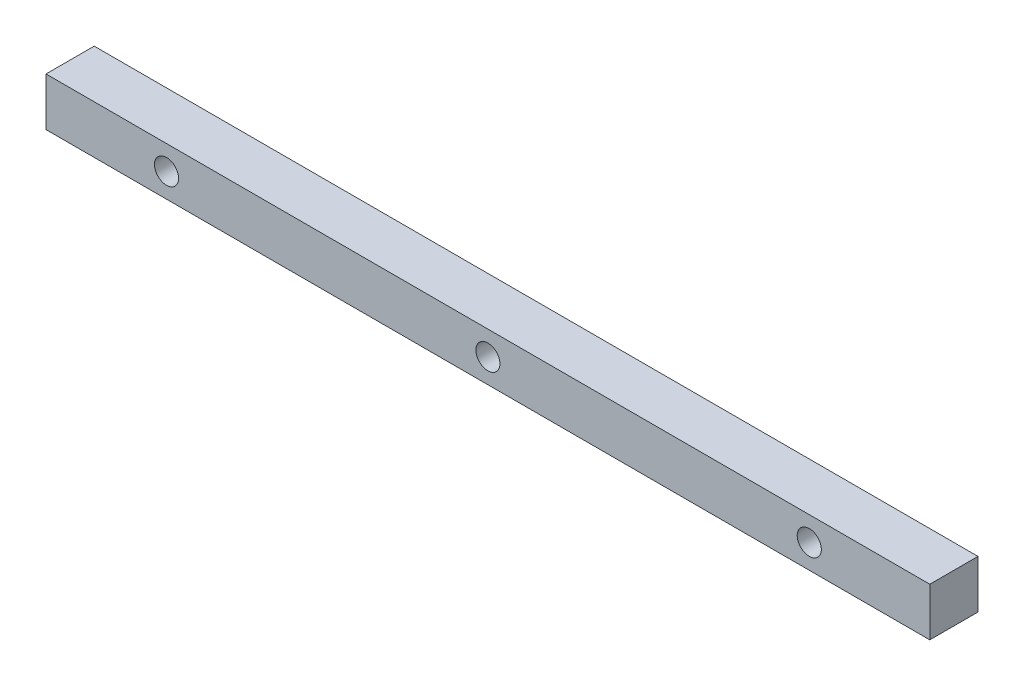
from build123d import *

# Parameters (mm, degrees)
ESQUISSE1_W             = 110
ESQUISSE1_H             = 6
BOSS_EXTRU_1_DEPTH      = 6
ESQUISSE2_R             = 1.5
ENL_V_MAT_EXTRU_1_DEPTH = 3


with BuildPart() as part:
    # Esquisse1 → Boss.-Extru.1 (new body)
    with BuildSketch(Plane.XY):
        with Locations((9.597087379, 13.990291262)):
            Rectangle(ESQUISSE1_W, ESQUISSE1_H)
    extrude(amount=BOSS_EXTRU_1_DEPTH)

    # Esquisse2 → Enlèv. mat.-Extru.1 (cut)
    with BuildSketch(Plane.XY.offset(6)):
        with Locations((-30.402912621, 13.990291262)):
            Circle(ESQUISSE2_R)
        with Locations((9.597087379, 13.990291262)):
            Circle(ESQUISSE2_R)
        with Locations((49.597087379, 13.990291262)):
            Circle(ESQUISSE2_R)
    extrude(amount=-ENL_V_MAT_EXTRU_1_DEPTH, mode=Mode.SUBTRACT)


solid = part.part
